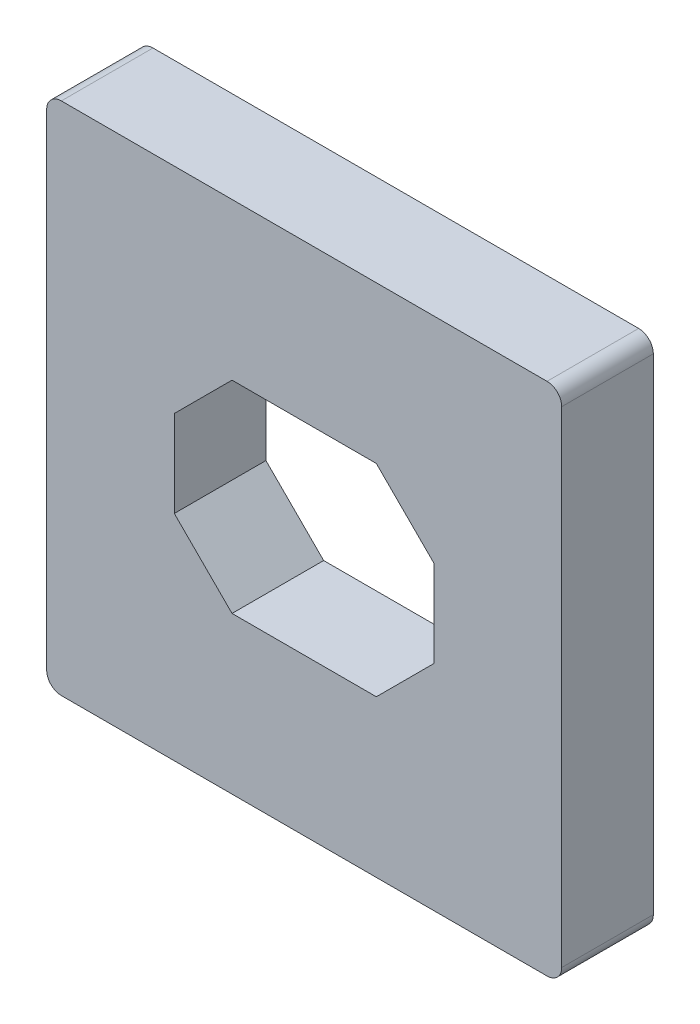
from build123d import *

# Parameters (mm, degrees)
BOSS_EXTRUDE1_DEPTH = 1.5875
SKETCH2_W           = 4.5
SKETCH2_H           = 3.5
CUT_EXTRUDE1_DEPTH  = 2.5875
CHAMFER1_SIZE       = 1


with BuildPart() as part:
    # Sketch1 → Boss-Extrude1 (new body)
    with BuildSketch(Plane.XY):
        with BuildLine():
            Line((4.207, 4.461), (-4.207, 4.461))
            ThreePointArc((-4.207, 4.461), (-4.386605122, 4.386605122), (-4.461, 4.207))
            Line((-4.461, 4.207), (-4.461, -4.207))
            ThreePointArc((-4.461, -4.207), (-4.386605122, -4.386605122), (-4.207, -4.461))
            Line((-4.207, -4.461), (4.207, -4.461))
            ThreePointArc((4.207, -4.461), (4.386605122, -4.386605122), (4.461, -4.207))
            Line((4.461, -4.207), (4.461, 4.207))
            ThreePointArc((4.461, 4.207), (4.386605122, 4.386605122), (4.207, 4.461))
        make_face()
    extrude(amount=BOSS_EXTRUDE1_DEPTH)

    # Sketch2 → Cut-Extrude1 (cut, through all)
    with BuildSketch(Plane.XY.offset(1.5875)):
        Rectangle(SKETCH2_W, SKETCH2_H)
    extrude(amount=-CUT_EXTRUDE1_DEPTH, mode=Mode.SUBTRACT)

    # Chamfer1
    chamfer1_edges = [part.edges().sort_by_distance(p)[0] for p in [
        (2.25, 1.75, 0.79375),
        (2.25, -1.75, 0.79375),
        (-2.25, -1.75, 0.79375),
        (-2.25, 1.75, 0.79375),
    ]]
    chamfer(chamfer1_edges, length=CHAMFER1_SIZE)


solid = part.part
